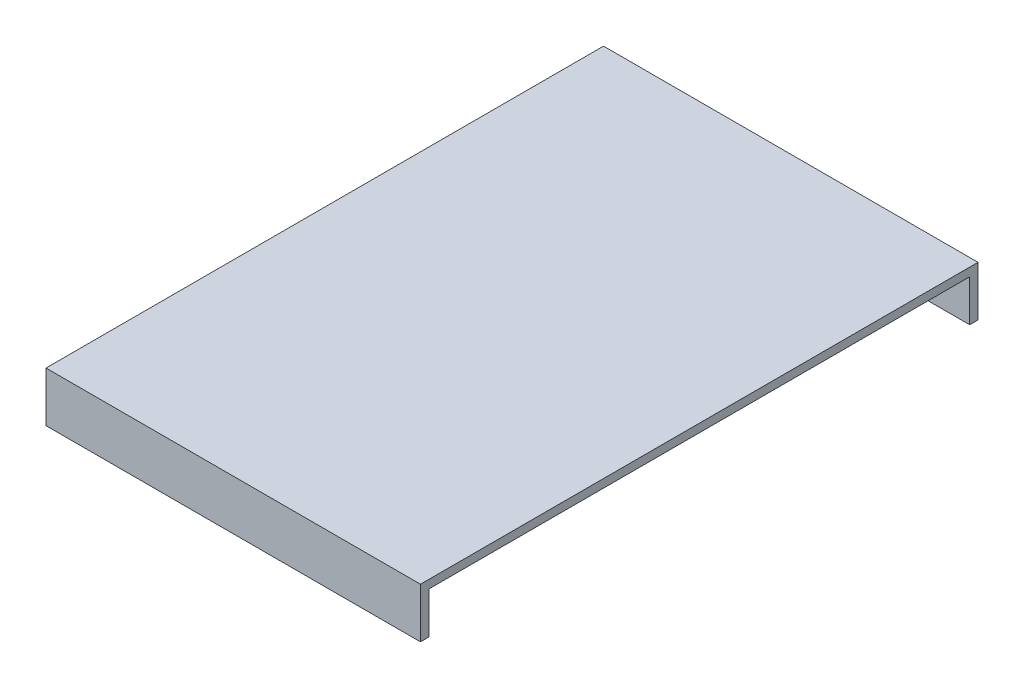
from build123d import *

# Parameters (mm, degrees)
EXTRUDE_1_DEPTH = 2
SKETCH_3_W      = 90
SKETCH_3_H      = 2
EXTRUDE_2_DEPTH = 10


with BuildPart() as part:
    # 草图2 → 凸台-拉伸1 (new body)
    with BuildSketch(Plane(origin=(0, 0, 0), x_dir=(1, 0, 0), z_dir=(0, 1, 0))):
        Polygon((-0.5, 69.85106383), (-45, 69.85106383), (-45, -64.14893617), (45, -64.14893617), (45, 69.85106383), align=None)
    extrude(amount=EXTRUDE_1_DEPTH)

    # 草图3 → 凸台-拉伸2 (add)
    with BuildSketch(Plane(origin=(0, 0, 0), x_dir=(1, 0, 0), z_dir=(0, 1, 0))):
        with Locations((0, 68.85106383)):
            Rectangle(SKETCH_3_W, SKETCH_3_H)
        with Locations((0, -63.14893617)):
            Rectangle(SKETCH_3_W, SKETCH_3_H)
    extrude(amount=-EXTRUDE_2_DEPTH)


solid = part.part
